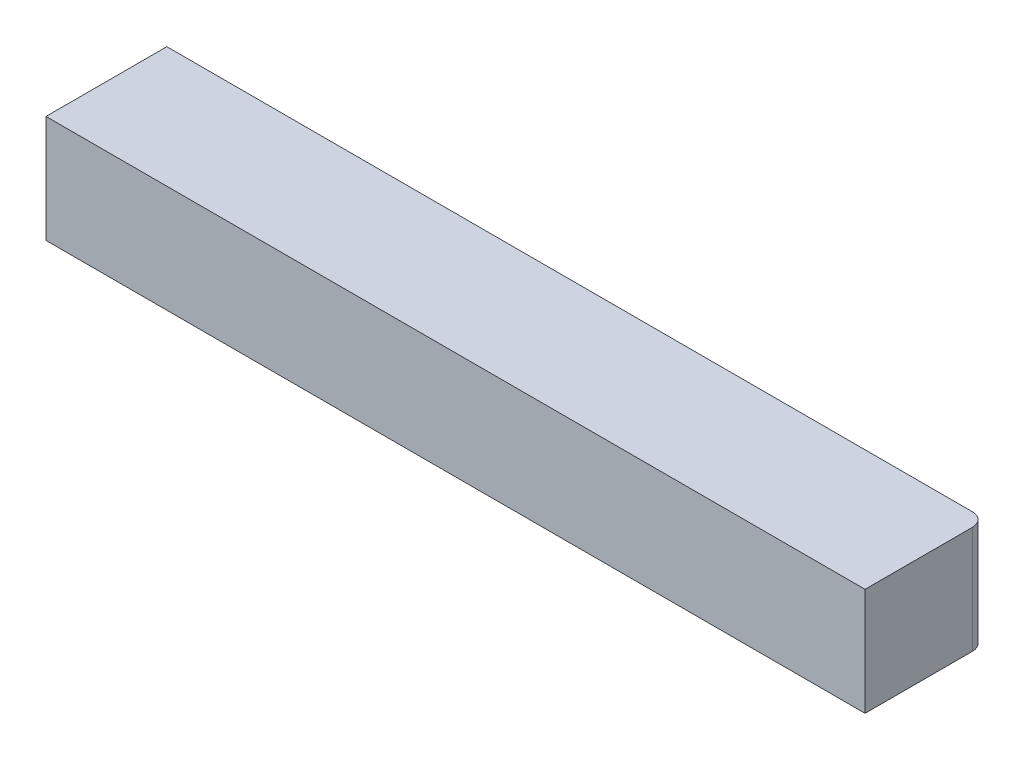
from build123d import *

# Parameters (mm, degrees)
BOSS_EXTRUDE1_DEPTH = 8


with BuildPart() as part:
    # Sketch1 → Boss-Extrude1 (new body)
    with BuildSketch(Plane(origin=(0, 0, 0), x_dir=(1, 0, 0), z_dir=(0, 1, 0))):
        with BuildLine():
            Line((-30.5, -4.5), (30.5, -4.5))
            Line((30.5, -4.5), (30.5, 3.5))
            ThreePointArc((30.5, 3.5), (30.207106781, 4.207106781), (29.5, 4.5))
            Line((29.5, 4.5), (-30.5, 4.5))
            Line((-30.5, 4.5), (-30.5, -4.5))
        make_face()
    extrude(amount=BOSS_EXTRUDE1_DEPTH)


solid = part.part
